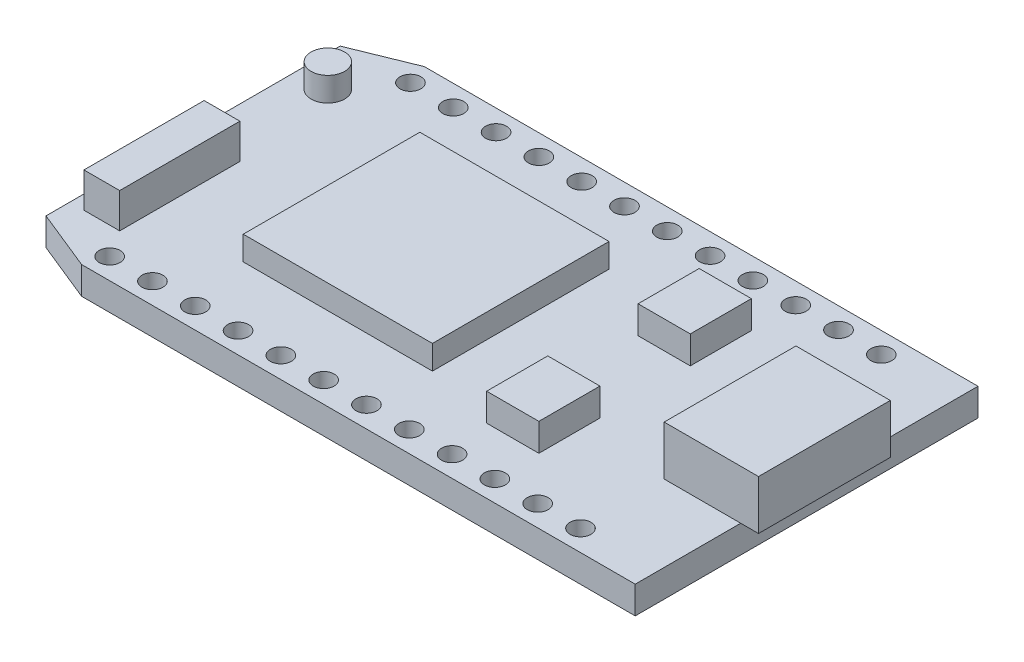
from build123d import *

# Parameters (mm, degrees)
SKETCH1_W           = 36.55
SKETCH1_H           = 20.42
BOSS_EXTRUDE1_DEPTH = 1.64
CHAMFER1_SIZE       = 1.45
CHAMFER1_SIZE2      = 3.57
CHAMFER2_SIZE       = 3.57
CHAMFER2_SIZE2      = 1.45
SKETCH3_W           = 5.62
SKETCH3_H           = 7.85
BOSS_EXTRUDE2_DEPTH = 2.94
SKETCH4_W           = 3.11
SKETCH4_H           = 3.64
BOSS_EXTRUDE3_DEPTH = 1.65
SKETCH5_W           = 2.13
SKETCH5_H           = 7.16
BOSS_EXTRUDE4_DEPTH = 2.08
SKETCH6_W           = 11.27
SKETCH6_H           = 10.52
BOSS_EXTRUDE5_DEPTH = 1.43
SKETCH7_R           = 1
BOSS_EXTRUDE6_DEPTH = 1.43
SKETCH8_R           = 0.625
CUT_EXTRUDE1_DEPTH  = 2.64


with BuildPart() as part:
    # Sketch1 → Boss-Extrude1 (new body)
    with BuildSketch(Plane(origin=(0, 0, 0), x_dir=(1, 0, 0), z_dir=(0, 1, 0))):
        Rectangle(SKETCH1_W, SKETCH1_H)
    extrude(amount=BOSS_EXTRUDE1_DEPTH)

    # Chamfer1
    chamfer1_edges = [part.edges().sort_by_distance(p)[0] for p in [
        (-18.275, 0.82, 10.21),
    ]]
    chamfer1_side = [part.faces().sort_by_distance(p)[0] for p in [
        (-18.275, 0.82, 0),
    ]]
    chamfer(chamfer1_edges, length=CHAMFER1_SIZE, length2=CHAMFER1_SIZE2, reference=chamfer1_side[0])

    # Chamfer2
    chamfer2_edges = [part.edges().sort_by_distance(p)[0] for p in [
        (-18.275, 0.82, -10.21),
    ]]
    chamfer2_side = [part.faces().sort_by_distance(p)[0] for p in [
        (0, 0.82, -10.21),
    ]]
    chamfer(chamfer2_edges, length=CHAMFER2_SIZE, length2=CHAMFER2_SIZE2, reference=chamfer2_side[0])

    # Sketch3 → Boss-Extrude2 (add)
    with BuildSketch(Plane(origin=(0, 1.64, 0), x_dir=(1, 0, 0), z_dir=(0, 1, 0))):
        with Locations((16.525, 0)):
            Rectangle(SKETCH3_W, SKETCH3_H)
    extrude(amount=BOSS_EXTRUDE2_DEPTH)

    # Sketch4 → Boss-Extrude3 (add)
    with BuildSketch(Plane(origin=(0, 1.64, 0), x_dir=(1, 0, 0), z_dir=(0, 1, 0))):
        with Locations((7.1, 4.51)):
            Rectangle(SKETCH4_W, SKETCH4_H)
        with Locations((7.1, -4.51)):
            Rectangle(SKETCH4_W, SKETCH4_H)
    extrude(amount=BOSS_EXTRUDE3_DEPTH)

    # Sketch5 → Boss-Extrude4 (add)
    with BuildSketch(Plane(origin=(0, 1.64, 0), x_dir=(1, 0, 0), z_dir=(0, 1, 0))):
        with Locations((-16.37, -3.76)):
            Rectangle(SKETCH5_W, SKETCH5_H)
    extrude(amount=BOSS_EXTRUDE4_DEPTH)

    # Sketch6 → Boss-Extrude5 (add)
    with BuildSketch(Plane(origin=(0, 1.64, 0), x_dir=(1, 0, 0), z_dir=(0, 1, 0))):
        with Locations((-4.39, 0)):
            Rectangle(SKETCH6_W, SKETCH6_H)
    extrude(amount=BOSS_EXTRUDE5_DEPTH)

    # Sketch7 → Boss-Extrude6 (add)
    with BuildSketch(Plane(origin=(0, 1.64, 0), x_dir=(1, 0, 0), z_dir=(0, 1, 0))):
        with Locations((-16.405, 6.16)):
            Circle(SKETCH7_R)
    extrude(amount=BOSS_EXTRUDE6_DEPTH)

    # Sketch8 → Cut-Extrude1 (cut, through all)
    with BuildSketch(Plane(origin=(0, 1.64, 0), x_dir=(1, 0, 0), z_dir=(0, 1, 0))):
        with Locations((13.765, -8.96)):
            Circle(SKETCH8_R)
        with Locations((11.215, -8.96)):
            Circle(SKETCH8_R)
        with Locations((8.665, -8.96)):
            Circle(SKETCH8_R)
        with Locations((6.115, -8.96)):
            Circle(SKETCH8_R)
        with Locations((3.565, -8.96)):
            Circle(SKETCH8_R)
        with Locations((1.015, -8.96)):
            Circle(SKETCH8_R)
        with Locations((-1.535, -8.96)):
            Circle(SKETCH8_R)
        with Locations((-4.085, -8.96)):
            Circle(SKETCH8_R)
        with Locations((-6.635, -8.96)):
            Circle(SKETCH8_R)
        with Locations((-9.185, -8.96)):
            Circle(SKETCH8_R)
        with Locations((-11.735, -8.96)):
            Circle(SKETCH8_R)
        with Locations((-14.285, -8.96)):
            Circle(SKETCH8_R)
        with Locations((-14.285, 8.96)):
            Circle(SKETCH8_R)
        with Locations((-11.735, 8.96)):
            Circle(SKETCH8_R)
        with Locations((-9.185, 8.96)):
            Circle(SKETCH8_R)
        with Locations((3.565, 8.96)):
            Circle(SKETCH8_R)
        with Locations((-6.635, 8.96)):
            Circle(SKETCH8_R)
        with Locations((-4.085, 8.96)):
            Circle(SKETCH8_R)
        with Locations((-1.535, 8.96)):
            Circle(SKETCH8_R)
        with Locations((1.015, 8.96)):
            Circle(SKETCH8_R)
        with Locations((6.115, 8.96)):
            Circle(SKETCH8_R)
        with Locations((8.665, 8.96)):
            Circle(SKETCH8_R)
        with Locations((11.215, 8.96)):
            Circle(SKETCH8_R)
        with Locations((13.765, 8.96)):
            Circle(SKETCH8_R)
    extrude(amount=-CUT_EXTRUDE1_DEPTH, mode=Mode.SUBTRACT)


solid = part.part
